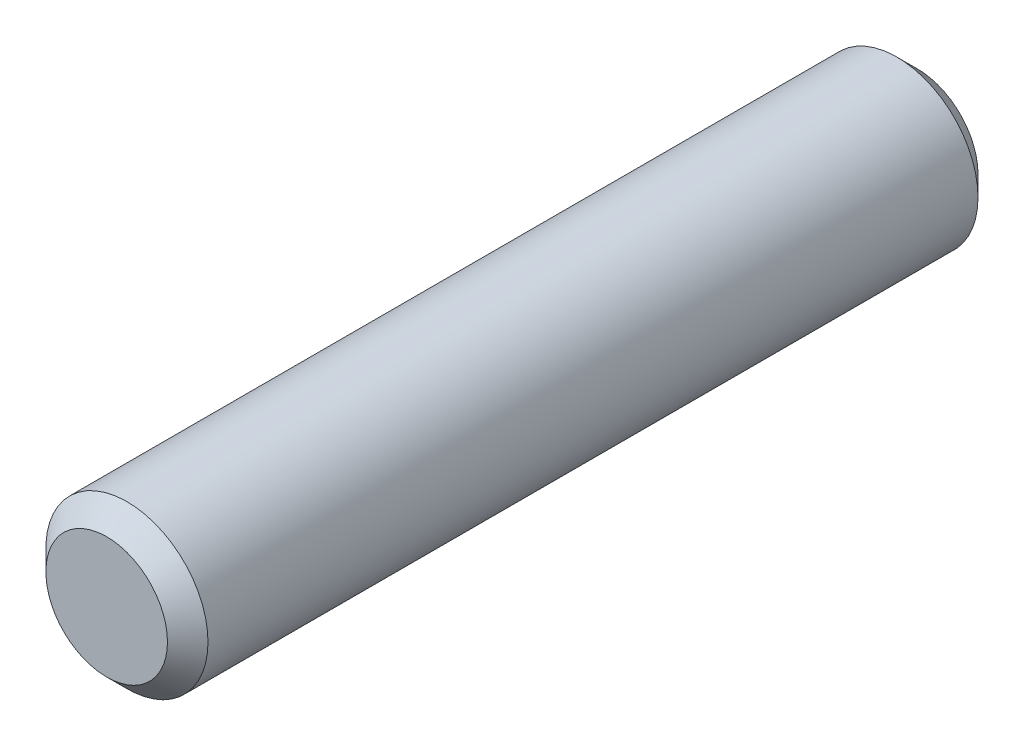
from build123d import *

# Parameters (mm, degrees)
ESQUISSE1_R          = 1
BASE_EXTRUSION_DEPTH = 10
CHANFREIN1_SIZE      = 0.25


with BuildPart() as part:
    # Esquisse1 → Base-Extrusion (new body)
    with BuildSketch(Plane.XY):
        Circle(ESQUISSE1_R)
    extrude(amount=BASE_EXTRUSION_DEPTH)

    # Chanfrein1
    chanfrein1_edges = [part.edges().sort_by_distance(p)[0] for p in [
        (-1, 0, 0),
        (-1, 0, 10),
    ]]
    chamfer(chanfrein1_edges, length=CHANFREIN1_SIZE)


solid = part.part
